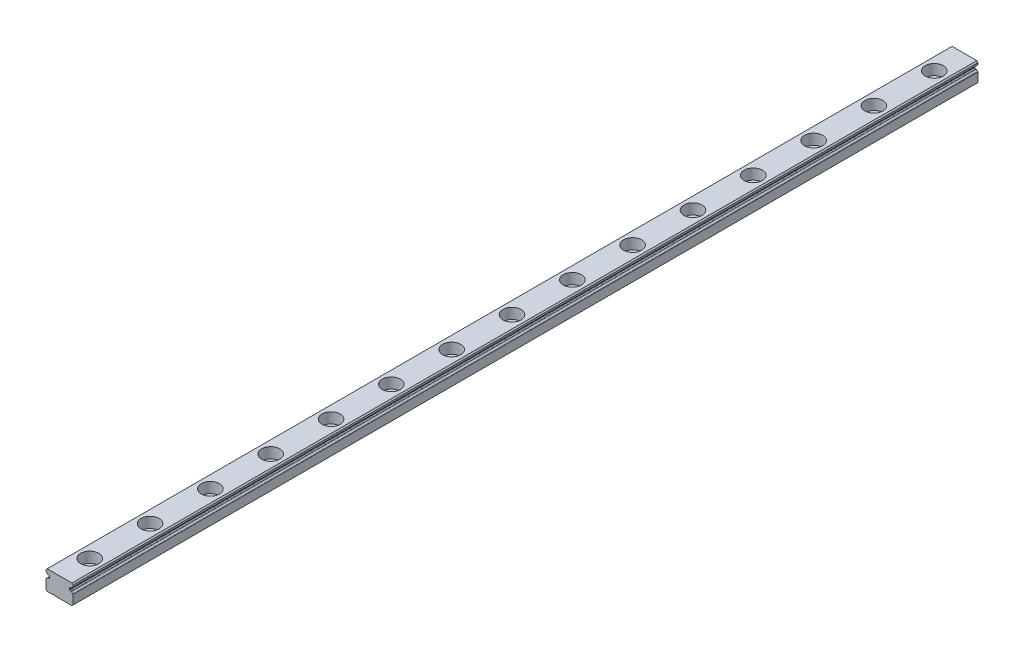
from build123d import *

# Parameters (mm, degrees)
BOSS_EXTRUDE1_DEPTH                              = 600
CUT_EXTRUDE1_DEPTH                               = 601
CUT_EXTRUDE2_DEPTH                               = 600
CUT_EXTRUDE3_DEPTH                               = 601
CUT_EXTRUDE4_DEPTH                               = 601
CUT_EXTRUDE5_DEPTH                               = 601
CBORE_FOR_M3_HEX_HEAD_MACHINE_SCREW1_D           = 3.5
CBORE_FOR_M3_HEX_HEAD_MACHINE_SCREW1_DEPTH       = 6.5
CBORE_FOR_M3_HEX_HEAD_MACHINE_SCREW1_CBORE_D     = 6
CBORE_FOR_M3_HEX_HEAD_MACHINE_SCREW1_CBORE_DEPTH = 3.5
CHAMFER1_SIZE                                    = 0.4
FILLET1_R                                        = 0.15
SKETCH9_W                                        = 15.091818395
SKETCH9_H                                        = 10.107210302
CUT_EXTRUDE6_DEPTH                               = 302.5
BOSS_EXTRUDE2_DEPTH                              = 2.5


with BuildPart() as part:
    # Sketch1 → Boss-Extrude1 (new body)
    with BuildSketch(Plane.XY.offset(300)):
        Polygon((-4.5, -0.4), (-4.5, -6.5), (4.5, -6.5), (4.5, -0.4), (4.1, 0), (-4.1, 0), align=None)
    extrude(amount=-BOSS_EXTRUDE1_DEPTH)

    # Sketch2 → Cut-Extrude1 (cut, through all)
    with BuildSketch(Plane(origin=(0, 0, -300), x_dir=(-1, 0, 0), z_dir=(0, 0, -1))):
        with BuildLine():
            Line((4.5, -2.953942201), (4.5, -1.504352668))
            Line((4.5, -1.504352668), (3.3, -1.609339064))
            Line((3.3, -1.609339064), (3.3, -2.390660936))
            Line((3.3, -2.390660936), (3.903713776, -2.443479047))
            ThreePointArc((3.903713776, -2.443479047), (4.149678279, -2.75966191), (4.5, -2.953942201))
        make_face()
    extrude(amount=-CUT_EXTRUDE1_DEPTH, mode=Mode.SUBTRACT)

    # Sketch3 → Cut-Extrude2 (cut)
    with BuildSketch(Plane(origin=(0, 0, -300), x_dir=(-1, 0, 0), z_dir=(0, 0, -1))):
        with BuildLine():
            Line((1.4, -6.5), (2.2, -6.5))
            ThreePointArc((2.2, -6.5), (1.8, -6.3), (1.4, -6.5))
        make_face()
    extrude(amount=-CUT_EXTRUDE2_DEPTH, mode=Mode.SUBTRACT)

    # Sketch4 → Cut-Extrude3 (cut, through all)
    with BuildSketch(Plane(origin=(0, 0, -300), x_dir=(-1, 0, 0), z_dir=(0, 0, -1))):
        with BuildLine():
            Line((-4.5, -1.504352668), (-4.5, -2.953942201))
            ThreePointArc((-4.5, -2.953942201), (-4.149678279, -2.75966191), (-3.903713776, -2.443479047))
            Line((-3.903713776, -2.443479047), (-3.3, -2.390660936))
            Line((-3.3, -2.390660936), (-3.3, -1.609339064))
            Line((-3.3, -1.609339064), (-4.5, -1.504352668))
        make_face()
    extrude(amount=-CUT_EXTRUDE3_DEPTH, mode=Mode.SUBTRACT)

    # Sketch5 → Cut-Extrude4 (cut, through all)
    with BuildSketch(Plane(origin=(0, 0, -300), x_dir=(-1, 0, 0), z_dir=(0, 0, -1))):
        with BuildLine():
            Line((-4.5, -1.046063799), (-4.5, -1.504352668))
            Line((-4.5, -1.504352668), (-3.903716879, -1.556520682))
            ThreePointArc((-3.903716879, -1.556520682), (-4.149680937, -1.240341815), (-4.5, -1.046063799))
        make_face()
    extrude(amount=-CUT_EXTRUDE4_DEPTH, mode=Mode.SUBTRACT)

    # Sketch6 → Cut-Extrude5 (cut, through all)
    with BuildSketch(Plane(origin=(0, 0, -300), x_dir=(-1, 0, 0), z_dir=(0, 0, -1))):
        with BuildLine():
            Line((3.903716879, -1.556520682), (4.5, -1.504352668))
            Line((4.5, -1.504352668), (4.5, -1.046063799))
            ThreePointArc((4.5, -1.046063799), (4.149680937, -1.240341815), (3.903716879, -1.556520682))
        make_face()
    extrude(amount=-CUT_EXTRUDE5_DEPTH, mode=Mode.SUBTRACT)

    # CBORE for M3 Hex Head Machine Screw1
    with Locations(Plane(origin=(0, 0, 0), x_dir=(1, 0, 0), z_dir=(0, 1, 0))):
        with Locations((0, -287.5), (0, -267.5), (0, -247.5), (0, -227.5), (0, -207.5), (0, -187.5), (0, -167.5), (0, -147.5), (0, -127.5), (0, -107.5), (0, -87.5), (0, -67.5), (0, -47.5), (0, -27.5), (0, -7.5), (0, 12.5), (0, 32.5), (0, 52.5), (0, 72.5), (0, 92.5), (0, 112.5), (0, 132.5), (0, 152.5), (0, 172.5), (0, 192.5), (0, 212.5), (0, 232.5), (0, 252.5), (0, 272.5), (0, 292.5)):
            CounterBoreHole(CBORE_FOR_M3_HEX_HEAD_MACHINE_SCREW1_D / 2, CBORE_FOR_M3_HEX_HEAD_MACHINE_SCREW1_CBORE_D / 2, CBORE_FOR_M3_HEX_HEAD_MACHINE_SCREW1_CBORE_DEPTH, depth=CBORE_FOR_M3_HEX_HEAD_MACHINE_SCREW1_DEPTH)

    # Chamfer1
    chamfer1_edges = [part.edges().sort_by_distance(p)[0] for p in [
        (4.5, -6.5, 0),
        (-4.5, -6.5, 0),
    ]]
    chamfer(chamfer1_edges, length=CHAMFER1_SIZE)

    # Fillet1
    fillet1_edges = [part.edges().sort_by_distance(p)[0] for p in [
        (-4.5, -2.953942201, 0),
        (-3.903713776, -2.443479047, 0),
        (-3.3, -2.390660936, 0),
        (-3.3, -1.609339064, 0),
        (3.3, -1.609339064, 0),
        (3.3, -2.390660936, 0),
        (3.903713776, -2.443479047, 0),
        (4.5, -2.953942201, 0),
        (4.5, -1.046063799, 0),
        (3.903716879, -1.556520682, 0),
        (-3.903716879, -1.556520682, 0),
        (-4.5, -1.046063799, 0),
    ]]
    fillet(fillet1_edges, radius=FILLET1_R)

    # Sketch9 → Cut-Extrude6 (cut)
    with BuildSketch(Plane.XY.offset(300)):
        with Locations((-0.509675465, -2.97999891)):
            Rectangle(SKETCH9_W, SKETCH9_H)
    extrude(amount=-CUT_EXTRUDE6_DEPTH, mode=Mode.SUBTRACT)

    # Sketch10 → Boss-Extrude2 (add)
    with BuildSketch(Plane(origin=(0, 0, -300), x_dir=(-1, 0, 0), z_dir=(0, 0, -1))):
        with BuildLine():
            Line((3.436926639, -1.597359536), (3.823514163, -1.56353751))
            ThreePointArc((3.823514163, -1.56353751), (3.890340367, -1.541057348), (3.939513741, -1.490529352))
            ThreePointArc((3.939513741, -1.490529352), (4.141265182, -1.247627801), (4.408695652, -1.079741674))
            ThreePointArc((4.408695652, -1.079741674), (4.475108648, -1.024454068), (4.5, -0.941702476))
            Line((4.5, -0.941702476), (4.5, -0.4))
            Line((4.5, -0.4), (4.1, 0))
            Line((4.1, 0), (-4.1, 0))
            Line((-4.1, 0), (-4.5, -0.4))
            Line((-4.5, -0.4), (-4.5, -0.941702476))
            ThreePointArc((-4.5, -0.941702476), (-4.475108648, -1.024454068), (-4.408695652, -1.079741674))
            ThreePointArc((-4.408695652, -1.079741674), (-4.141265182, -1.247627801), (-3.939513741, -1.490529352))
            ThreePointArc((-3.939513741, -1.490529352), (-3.890340367, -1.541057348), (-3.823514163, -1.56353751))
            Line((-3.823514163, -1.56353751), (-3.436926639, -1.597359536))
            ThreePointArc((-3.436926639, -1.597359536), (-3.339408399, -1.645450209), (-3.3, -1.746788741))
            Line((-3.3, -1.746788741), (-3.3, -2.253211259))
            ThreePointArc((-3.3, -2.253211259), (-3.339408399, -2.354549791), (-3.436926639, -2.402640464))
            Line((-3.436926639, -2.402640464), (-3.823510417, -2.436462162))
            ThreePointArc((-3.823510417, -2.436462162), (-3.890337026, -2.458942579), (-3.939510483, -2.509471145))
            ThreePointArc((-3.939510483, -2.509471145), (-4.141262777, -2.752376093), (-4.408695652, -2.920264326))
            ThreePointArc((-4.408695652, -2.920264326), (-4.475108648, -2.975551932), (-4.5, -3.058303524))
            Line((-4.5, -3.058303524), (-4.5, -6.1))
            Line((-4.5, -6.1), (-4.1, -6.5))
            Line((-4.1, -6.5), (1.4, -6.5))
            ThreePointArc((1.4, -6.5), (1.8, -6.3), (2.2, -6.5))
            Line((2.2, -6.5), (4.1, -6.5))
            Line((4.1, -6.5), (4.5, -6.1))
            Line((4.5, -6.1), (4.5, -3.058303524))
            ThreePointArc((4.5, -3.058303524), (4.475108648, -2.975551932), (4.408695652, -2.920264326))
            ThreePointArc((4.408695652, -2.920264326), (4.141262777, -2.752376093), (3.939510483, -2.509471145))
            ThreePointArc((3.939510483, -2.509471145), (3.890337026, -2.458942579), (3.823510417, -2.436462162))
            Line((3.823510417, -2.436462162), (3.436926639, -2.402640464))
            ThreePointArc((3.436926639, -2.402640464), (3.339408399, -2.354549791), (3.3, -2.253211259))
            Line((3.3, -2.253211259), (3.3, -1.746788741))
            ThreePointArc((3.3, -1.746788741), (3.339408399, -1.645450209), (3.436926639, -1.597359536))
        make_face()
    extrude(amount=BOSS_EXTRUDE2_DEPTH)


solid = part.part
